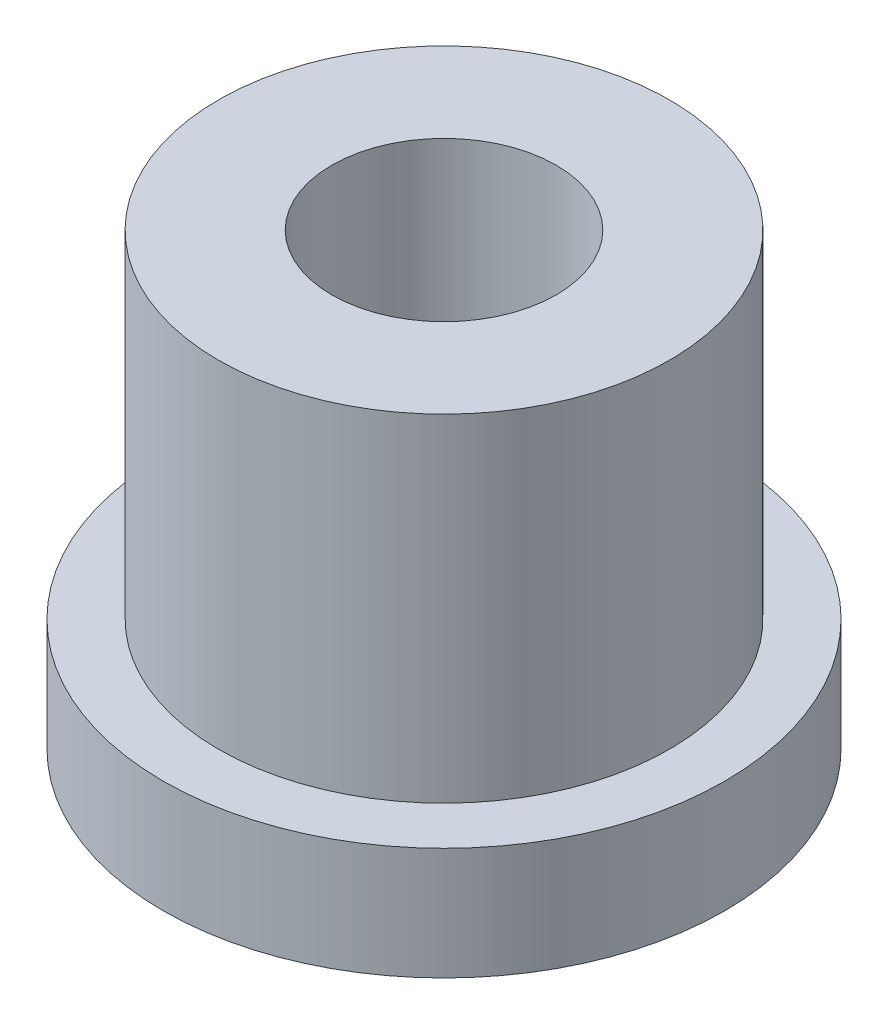
from build123d import *

# Parameters (mm, degrees)
SKETCH2_R           = 3.1877
SKETCH2_R_2         = 1.5875
BOSS_EXTRUDE1_DEPTH = 6.35
SKETCH3_R           = 3.96875
SKETCH3_R_2         = 3.1877
BOSS_EXTRUDE2_DEPTH = 1.5875


with BuildPart() as part:
    # Sketch2 → Boss-Extrude1 (new body)
    with BuildSketch(Plane(origin=(0, 0, 0), x_dir=(1, 0, 0), z_dir=(0, 1, 0))):
        Circle(SKETCH2_R)
        Circle(SKETCH2_R_2, mode=Mode.SUBTRACT)
    extrude(amount=BOSS_EXTRUDE1_DEPTH)

    # Sketch3 → Boss-Extrude2 (add)
    with BuildSketch(Plane(origin=(0, 0, 0), x_dir=(1, 0, 0), z_dir=(0, 1, 0))):
        Circle(SKETCH3_R)
        Circle(SKETCH3_R_2, mode=Mode.SUBTRACT)
    extrude(amount=BOSS_EXTRUDE2_DEPTH)


solid = part.part
